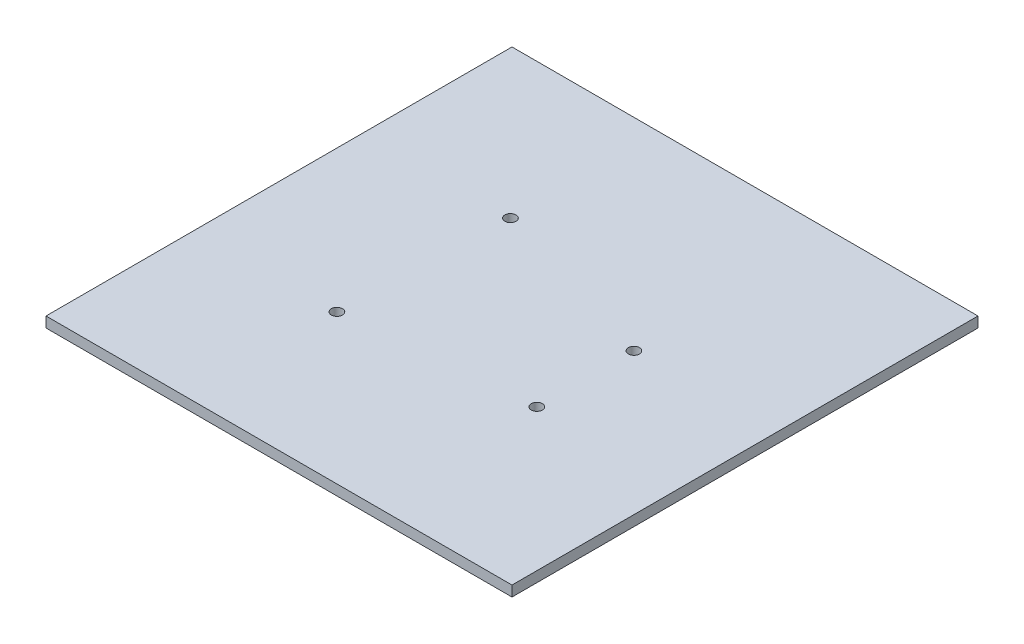
from build123d import *

# Parameters (mm, degrees)
SKETCH2_W           = 134
SKETCH2_H           = 134
SKETCH2_R           = 1.6
BOSS_EXTRUDE2_DEPTH = 3


with BuildPart() as part:
    # Sketch2 → Boss-Extrude2 (new body)
    with BuildSketch(Plane(origin=(0, 0, 0), x_dir=(1, 0, 0), z_dir=(0, 1, 0))):
        Rectangle(SKETCH2_W, SKETCH2_H)
        with Locations((-24.6, 24.15)):
            Circle(SKETCH2_R, mode=Mode.SUBTRACT)
        with Locations((-26.2, -24.15)):
            Circle(SKETCH2_R, mode=Mode.SUBTRACT)
        with Locations((26.2, 8.85)):
            Circle(SKETCH2_R, mode=Mode.SUBTRACT)
        with Locations((26.2, -19.05)):
            Circle(SKETCH2_R, mode=Mode.SUBTRACT)
    extrude(amount=BOSS_EXTRUDE2_DEPTH)


solid = part.part
